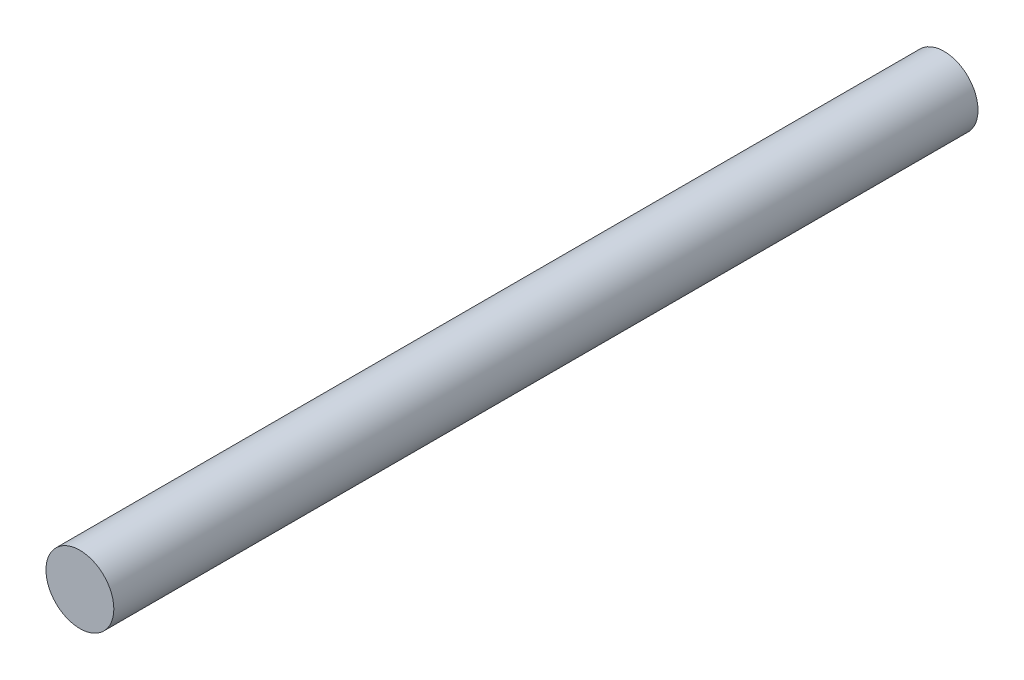
from build123d import *

# Parameters (mm, degrees)
ESQUISSE1_R        = 2.75
BOSS_EXTRU_1_DEPTH = 70


with BuildPart() as part:
    # Esquisse1 → Boss.-Extru.1 (new body)
    with BuildSketch(Plane.XY):
        with Locations((-5.315732905, -0.62411439)):
            Circle(ESQUISSE1_R)
    extrude(amount=BOSS_EXTRU_1_DEPTH)


solid = part.part
